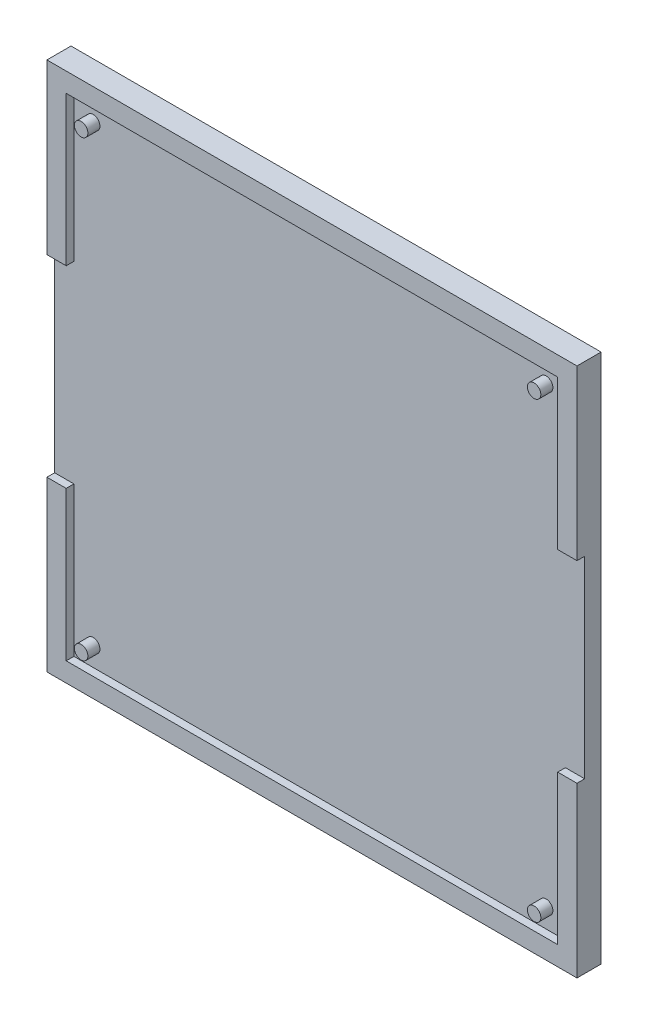
from build123d import *

# Parameters (mm, degrees)
SKETCH1_W           = 110
SKETCH1_H           = 110
BOSS_EXTRUDE1_DEPTH = 5
SKETCH3_W           = 102
SKETCH3_H           = 102
CUT_EXTRUDE1_DEPTH  = 1.6
SKETCH4_R           = 1.4
BOSS_EXTRUDE3_DEPTH = 2.5
SKETCH11_W          = 5
SKETCH11_H          = 40
CUT_EXTRUDE3_DEPTH  = 1.6


with BuildPart() as part:
    # Sketch1 → Boss-Extrude1 (new body)
    with BuildSketch(Plane(origin=(0, 0, 0), x_dir=(1, 0, 0), z_dir=(0, 0, -1))):
        with Locations((55, 55)):
            Rectangle(SKETCH1_W, SKETCH1_H)
    extrude(amount=-BOSS_EXTRUDE1_DEPTH)

    # Sketch3 → Cut-Extrude1 (cut)
    with BuildSketch(Plane(origin=(0, 0, 5), x_dir=(-1, 0, 0), z_dir=(0, 0, 1))):
        with Locations((-55, 55)):
            Rectangle(SKETCH3_W, SKETCH3_H)
    extrude(amount=-CUT_EXTRUDE1_DEPTH, mode=Mode.SUBTRACT)

    # Sketch4 → Boss-Extrude3 (add)
    with BuildSketch(Plane(origin=(0, 0, 3.4), x_dir=(-1, 0, 0), z_dir=(0, 0, 1))):
        with Locations((-102, 102)):
            Circle(SKETCH4_R)
        with Locations((-8, 102)):
            Circle(SKETCH4_R)
        with Locations((-102, 8)):
            Circle(SKETCH4_R)
        with Locations((-8, 8)):
            Circle(SKETCH4_R)
    extrude(amount=BOSS_EXTRUDE3_DEPTH)

    # Sketch11 → Cut-Extrude3 (cut)
    with BuildSketch(Plane(origin=(0, 0, 5), x_dir=(-1, 0, 0), z_dir=(0, 0, 1))):
        with Locations((-108.5, 55)):
            Rectangle(SKETCH11_W, SKETCH11_H)
        with Locations((-1.5, 55)):
            Rectangle(SKETCH11_W, SKETCH11_H)
    extrude(amount=-CUT_EXTRUDE3_DEPTH, mode=Mode.SUBTRACT)


solid = part.part
